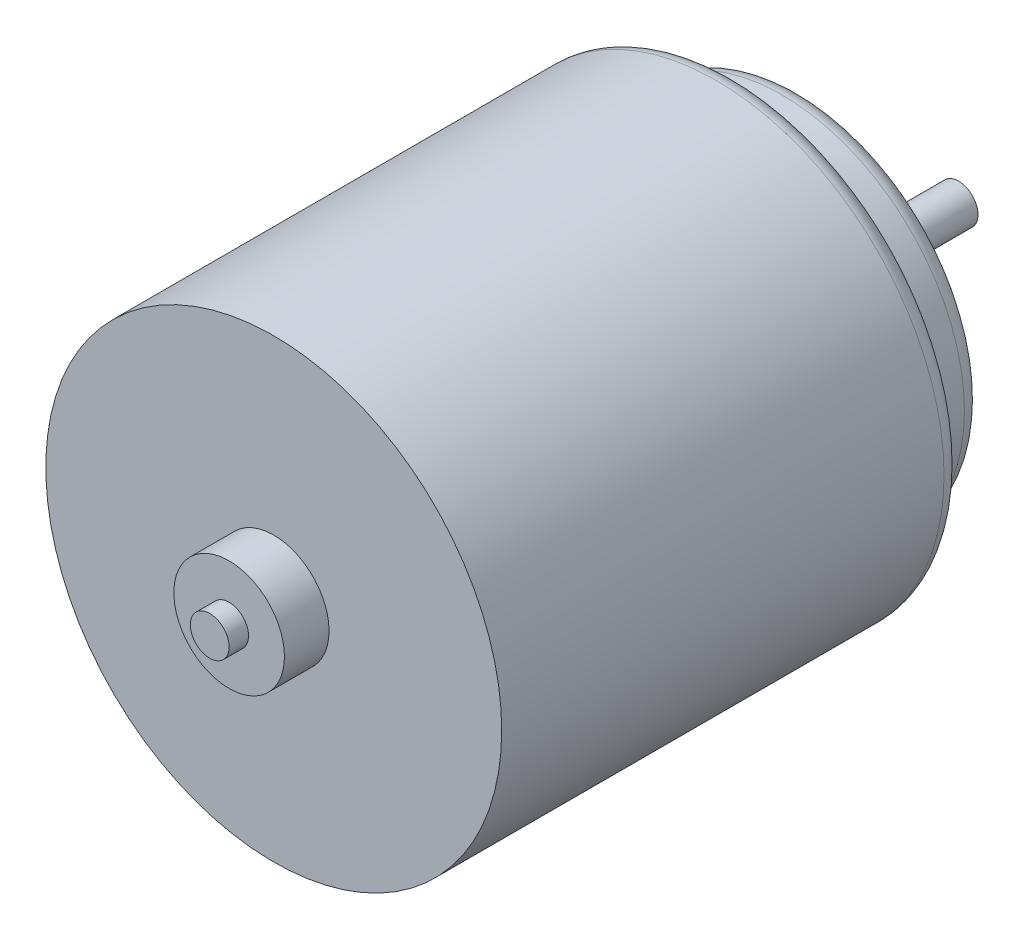
from build123d import *

# Parameters (mm, degrees)
SKETCH1_R                = 11.75
SKETCH1_R_2              = 9.4
BOSS_EXTRUDE1_DEPTH      = 23.8
SKETCH1_3_R              = 9.4
SKETCH1_3_R_2            = 4.25
BOSS_EXTRUDE2_DEPTH      = 27.2
SKETCH1_4_R              = 4.25
SKETCH1_4_R_2            = 2.85
BOSS_EXTRUDE3_DEPTH      = 29.4
BOSS_EXTRUDE4_DEPTH      = 2.3
BOSS_EXTRUDE4_DEPTH_BACK = 29.4
SKETCH1_5_R              = 2.85
BOSS_EXTRUDE5_DEPTH      = 3.3
BOSS_EXTRUDE5_DEPTH_BACK = 35.3
SKETCH1_6_R              = 1
FILLET1_R                = 1


with BuildPart() as part:
    # Sketch1 → Boss-Extrude1 (new body)
    with BuildSketch(Plane.XY):
        Circle(SKETCH1_R)
        Circle(SKETCH1_R_2, mode=Mode.SUBTRACT)
    extrude(amount=-BOSS_EXTRUDE1_DEPTH)

    # Sketch1_3 → Boss-Extrude2 (add)
    with BuildSketch(Plane.XY):
        Circle(SKETCH1_3_R)
        Circle(SKETCH1_3_R_2, mode=Mode.SUBTRACT)
    extrude(amount=-BOSS_EXTRUDE2_DEPTH)

    # Sketch1_4 → Boss-Extrude3 (add)
    with BuildSketch(Plane.XY):
        Circle(SKETCH1_4_R)
        Circle(SKETCH1_4_R_2, mode=Mode.SUBTRACT)
    extrude(amount=-BOSS_EXTRUDE3_DEPTH)

    # Sketch1_5 → Boss-Extrude4 (add, two sides: drawn at the far end of the back side and taken through both)
    with BuildSketch(Plane.XY.offset(-BOSS_EXTRUDE4_DEPTH_BACK)):
        Circle(SKETCH1_5_R)
    extrude(amount=BOSS_EXTRUDE4_DEPTH + BOSS_EXTRUDE4_DEPTH_BACK)

    # Sketch1_6 → Boss-Extrude5 (add, two sides: drawn at the far end of the back side and taken through both)
    with BuildSketch(Plane.XY.offset(-BOSS_EXTRUDE5_DEPTH_BACK)):
        Circle(SKETCH1_6_R)
    extrude(amount=BOSS_EXTRUDE5_DEPTH + BOSS_EXTRUDE5_DEPTH_BACK)

    # Fillet1
    fillet1_edges = [part.edges().sort_by_distance(p)[0] for p in [
        (-9.4, 0, -27.2),
        (-11.75, 0, -23.8),
    ]]
    fillet(fillet1_edges, radius=FILLET1_R)


solid = part.part
